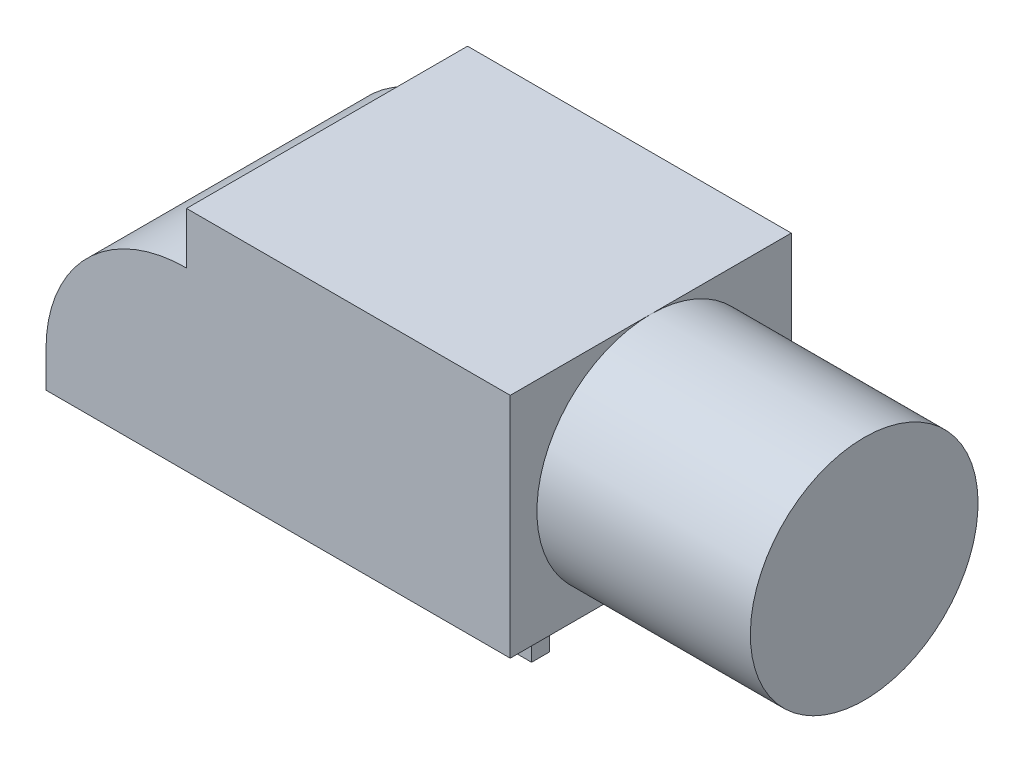
from build123d import *

# Parameters (mm, degrees)
SKETCH1_W               = 19.05
SKETCH1_H               = 6.4
BOSS_EXTRUDE1_DEPTH     = 3.95
SKETCH2_OUTSIDE_W       = 14.218
SKETCH2_OUTSIDE_H       = 12.718
SKETCH2_OUTSIDE_R       = 3.2
CUT_EXTRUDE1_DEPTH      = 6
SKETCH3_R               = 0.75
SKETCH3_W               = 1.2
SKETCH3_H               = 0.5
BOSS_EXTRUDE2_DEPTH     = 1
CUT_EXTRUDE2_DEPTH      = 1
CUT_EXTRUDE2_DEPTH_BACK = 8.9


with BuildPart() as part:
    # Sketch1 → Boss-Extrude1 (new body, symmetric)
    with BuildSketch(Plane.XY):
        Rectangle(SKETCH1_W, SKETCH1_H)
    extrude(amount=BOSS_EXTRUDE1_DEPTH, both=True)

    # Sketch2 outside → Cut-Extrude1 (cut)
    with BuildSketch(Plane(origin=(9.525, 0, 0), x_dir=(0, 0, -1), z_dir=(1, 0, 0))):
        Rectangle(SKETCH2_OUTSIDE_W, SKETCH2_OUTSIDE_H)
        Circle(SKETCH2_OUTSIDE_R, mode=Mode.SUBTRACT)
    extrude(amount=-CUT_EXTRUDE1_DEPTH, mode=Mode.SUBTRACT)

    # Sketch3 → Boss-Extrude2 (add)
    with BuildSketch(Plane.XZ.offset(3.2)):
        with Locations((-7.875, 0)):
            Circle(SKETCH3_R)
        with Locations((2.325, 2.5)):
            Rectangle(SKETCH3_W, SKETCH3_H)
        with Locations((2.325, -2.5)):
            Rectangle(SKETCH3_W, SKETCH3_H)
    extrude(amount=BOSS_EXTRUDE2_DEPTH)

    # Sketch5 → Cut-Extrude2 (cut, two sides)
    with BuildSketch(Plane.XY.offset(3.95)) as cut_extrude2_sk:
        with BuildLine():
            Line((-5.575, 53.392661022), (-5.575, 3.2))
            Line((-5.575, 3.2), (-5.575, 1.75))
            ThreePointArc((-5.575, 1.75), (-8.368071786, 0.593071786), (-9.525, -2.2))
            Line((-9.525, -2.2), (-9.525, -3.2))
            Line((-9.525, -3.2), (-9.525, -53.392661022))
            Line((-9.525, -53.392661022), (-109.841715444, -49.681935442))
            Line((-109.841715444, -49.681935442), (-105.891715444, 57.103386601))
            Line((-105.891715444, 57.103386601), (-5.575, 53.392661022))
        make_face()
    extrude(amount=CUT_EXTRUDE2_DEPTH, mode=Mode.SUBTRACT)
    extrude(cut_extrude2_sk.sketch, amount=-CUT_EXTRUDE2_DEPTH_BACK, mode=Mode.SUBTRACT)


solid = part.part
